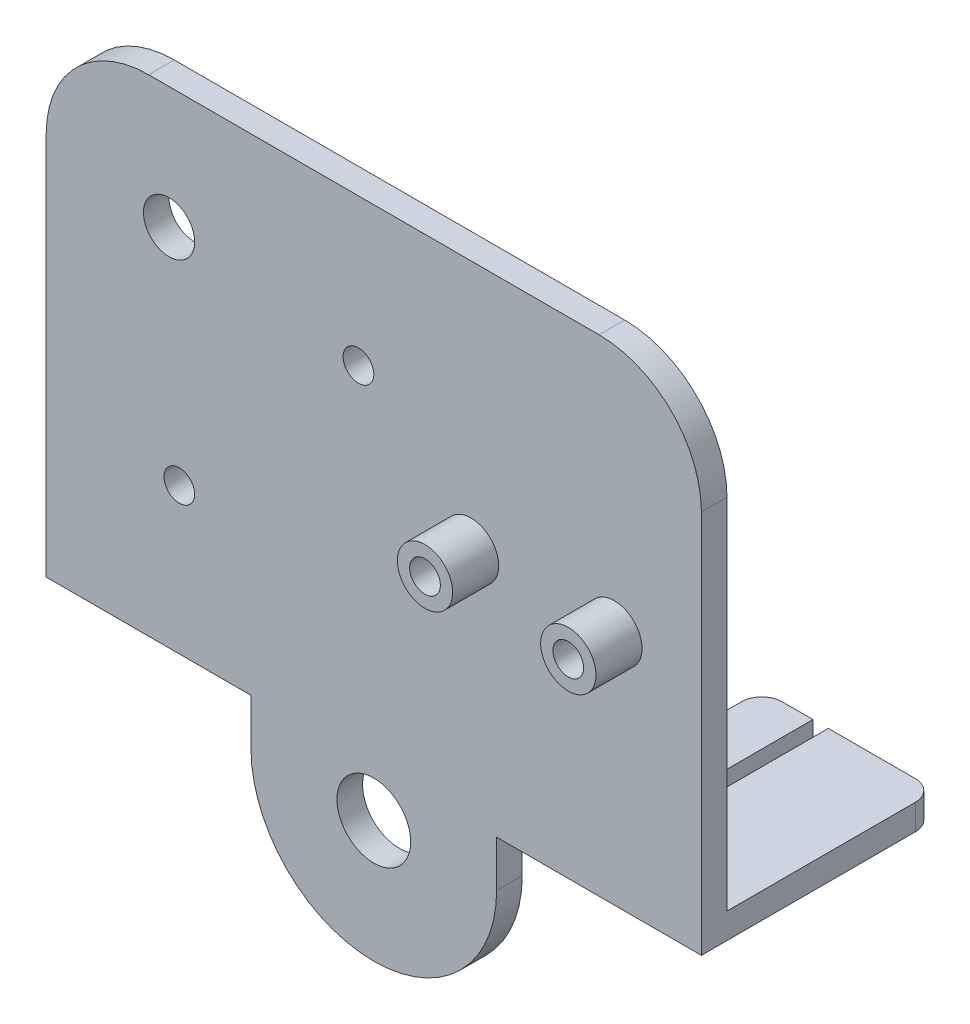
from build123d import *

# Parameters (mm, degrees)
BOSS_EXTRUDE1_DEPTH     = 2.5
SKETCH2_W               = 2.5
SKETCH2_H               = 47.5
BOSS_EXTRUDE2_DEPTH     = 20
SKETCH3_W               = 2.5
SKETCH3_H               = 47.5
BOSS_EXTRUDE3_DEPTH     = 20
SKETCH4_W               = 17
SKETCH4_H               = 2.5
BOSS_EXTRUDE4_DEPTH     = 20.4
SKETCH5_W               = 1.5
SKETCH5_H               = 11
CUT_EXTRUDE1_DEPTH      = 48.5
SKETCH6_W               = 17
SKETCH6_H               = 2.5
BOSS_EXTRUDE5_DEPTH     = 20.4
SKETCH7_W               = 1.5
SKETCH7_H               = 11
CUT_EXTRUDE2_DEPTH      = 48.5
SKETCH8_W               = 2.7
SKETCH8_H               = 4.5
SKETCH9_W               = 2.7
SKETCH9_H               = 4.5
SKETCH10_W              = 2
SKETCH10_H              = 1.5
SKETCH11_W              = 2
SKETCH11_H              = 1.5
FILLET1_R               = 2
FILLET2_R               = 10
SKETCH13_R              = 3.6
SKETCH13_R_2            = 2.5
SKETCH13_R_3            = 1.5
CUT_EXTRUDE3_DEPTH      = 5.5
CUT_EXTRUDE3_DEPTH_BACK = 23.9


with BuildPart() as part:
    # Sketch1 → Boss-Extrude1 (new body)
    with BuildSketch(Plane(origin=(0, 0, 0), x_dir=(-1, 0, 0), z_dir=(0, 0, -1))):
        with BuildLine():
            Line((12, -20), (12, 32))
            Line((12, 32), (-12, 32))
            Line((-12, 32), (-12, -20))
            ThreePointArc((-12, -20), (0, -32), (12, -20))
        make_face()
    extrude(amount=-BOSS_EXTRUDE1_DEPTH)

    # Sketch2 → Boss-Extrude2 (add)
    with BuildSketch(Plane.ZY.offset(12)):
        with Locations((1.25, 8.25)):
            Rectangle(SKETCH2_W, SKETCH2_H)
    extrude(amount=BOSS_EXTRUDE2_DEPTH)

    # Sketch3 → Boss-Extrude3 (add)
    with BuildSketch(Plane(origin=(12, 0, 0), x_dir=(0, 0, -1), z_dir=(1, 0, 0))):
        with Locations((-1.25, 8.25)):
            Rectangle(SKETCH3_W, SKETCH3_H)
    extrude(amount=BOSS_EXTRUDE3_DEPTH)

    # Sketch4 → Boss-Extrude4 (add)
    with BuildSketch(Plane(origin=(0, 0, 0), x_dir=(-1, 0, 0), z_dir=(0, 0, -1))):
        with Locations((-23.5, -14.25)):
            Rectangle(SKETCH4_W, SKETCH4_H)
    extrude(amount=BOSS_EXTRUDE4_DEPTH)

    # Sketch5 → Cut-Extrude1 (cut, through all)
    with BuildSketch(Plane.XZ.offset(15.5)):
        with Locations((20.75, -14.9)):
            Rectangle(SKETCH5_W, SKETCH5_H)
    extrude(amount=-CUT_EXTRUDE1_DEPTH, mode=Mode.SUBTRACT)

    # Sketch6 → Boss-Extrude5 (add)
    with BuildSketch(Plane(origin=(0, 0, 0), x_dir=(-1, 0, 0), z_dir=(0, 0, -1))):
        with Locations((23.5, -14.25)):
            Rectangle(SKETCH6_W, SKETCH6_H)
    extrude(amount=BOSS_EXTRUDE5_DEPTH)

    # Sketch7 → Cut-Extrude2 (cut, through all)
    with BuildSketch(Plane.XZ.offset(15.5)):
        with Locations((-20.75, -14.9)):
            Rectangle(SKETCH7_W, SKETCH7_H)
    extrude(amount=-CUT_EXTRUDE2_DEPTH, mode=Mode.SUBTRACT)

    # Sketch8 → Revolve1 (revolve)
    with BuildSketch(Plane(origin=(0, 7.55, 0), x_dir=(1, 0, 0), z_dir=(0, 1, 0))):
        with Locations((10.85, -4.75)):
            Rectangle(SKETCH8_W, SKETCH8_H)
    revolve(axis=Axis((9.5, 7.55, 2.5), (0, 0, 1)))

    # Sketch9 → Revolve2 (revolve)
    with BuildSketch(Plane(origin=(0, 7.55, 0), x_dir=(1, 0, 0), z_dir=(0, 1, 0))):
        with Locations((24.85, -4.75)):
            Rectangle(SKETCH9_W, SKETCH9_H)
    revolve(axis=Axis((23.5, 7.55, 2.5), (0, 0, 1)))

    # Sketch10 → Revolve3 (revolve)
    with BuildSketch(Plane.XZ.offset(1.25)):
        with Locations((-18, -0.75)):
            Rectangle(SKETCH10_W, SKETCH10_H)
    revolve(axis=Axis((-19, -1.25, 0), (0, 0, -1)))

    # Sketch11 → Revolve4 (revolve)
    with BuildSketch(Plane.XZ.offset(-17.65)):
        with Locations((-0.5, -0.75)):
            Rectangle(SKETCH11_W, SKETCH11_H)
    revolve(axis=Axis((-1.5, 17.65, 0), (0, 0, -1)))

    # Fillet1
    fillet1_edges = [part.edges().sort_by_distance(p)[0] for p in [
        (32, -14.25, -20.4),
        (15, -14.25, -20.4),
        (-15, -14.25, -20.4),
        (-32, -14.25, -20.4),
    ]]
    fillet(fillet1_edges, radius=FILLET1_R)

    # Fillet2
    fillet2_edges = [part.edges().sort_by_distance(p)[0] for p in [
        (-32, 32, 1.25),
        (32, 32, 1.25),
    ]]
    fillet(fillet2_edges, radius=FILLET2_R)

    # Sketch13 → Cut-Extrude3 (cut, two sides)
    with BuildSketch(Plane.XY.offset(2.5)) as cut_extrude3_sk:
        with Locations((0, -20.1)):
            Circle(SKETCH13_R)
        with Locations((-20, 20.1)):
            Circle(SKETCH13_R_2)
        with Locations((-1.5, 17.65)):
            Circle(SKETCH13_R_3)
        with Locations((-19, -1.25)):
            Circle(SKETCH13_R_3)
        with Locations((9.5, 7.55)):
            Circle(SKETCH13_R_3)
        with Locations((23.5, 7.55)):
            Circle(SKETCH13_R_3)
    extrude(amount=CUT_EXTRUDE3_DEPTH, mode=Mode.SUBTRACT)
    extrude(cut_extrude3_sk.sketch, amount=-CUT_EXTRUDE3_DEPTH_BACK, mode=Mode.SUBTRACT)


solid = part.part
